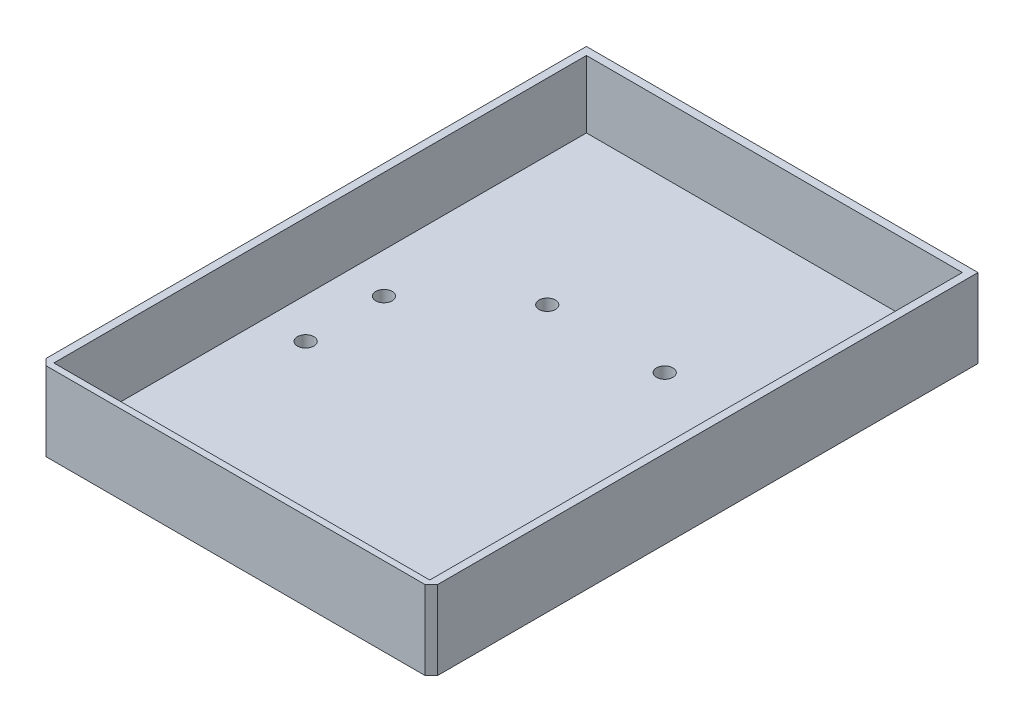
from build123d import *

# Parameters (mm, degrees)
SKETCH6_W            = 100
SKETCH6_H            = 100
SKETCH6_R            = 2.1
BOSS_EXTRUDE2_DEPTH  = 3
SKETCH7_W            = 96
SKETCH7_H            = 2
BOSS_EXTRUDE3_DEPTH  = 3
SKETCH8_W            = 96
SKETCH8_H            = 2
BOSS_EXTRUDE4_DEPTH  = 3
CHAMFER1_SIZE        = 2
BOSS_EXTRUDE5_DEPTH  = 3
SKETCH10_W           = 98
SKETCH10_H           = 25
BOSS_EXTRUDE6_DEPTH  = 2
SKETCH11_W           = 2
SKETCH11_H           = 25
BOSS_EXTRUDE7_DEPTH  = 40
SKETCH12_W           = 138
SKETCH12_H           = 25
BOSS_EXTRUDE8_DEPTH  = 2
CUT_EXTRUDE1_DEPTH   = 3
SKETCH15_W           = 96
SKETCH15_H           = 6.337470387
CUT_EXTRUDE2_DEPTH   = 3
SKETCH16_W           = 96
SKETCH16_H           = 3
BOSS_EXTRUDE9_DEPTH  = 40
SKETCH17_W           = 96
SKETCH17_H           = 2
BOSS_EXTRUDE10_DEPTH = 22
BOSS_EXTRUDE11_DEPTH = 19
SKETCH19_W           = 108.527729828
SKETCH19_H           = 34.099347136
CUT_EXTRUDE3_DEPTH   = 0.4
SKETCH20_W           = 119.4554648
SKETCH20_H           = 149.467416286
CUT_EXTRUDE4_DEPTH   = 4.87


with BuildPart() as part:
    # Sketch6 → Boss-Extrude2 (new body)
    with BuildSketch(Plane(origin=(0, 0, 0), x_dir=(1, 0, 0), z_dir=(0, 1, 0))):
        with Locations((39.444153985, -113.424821635)):
            Rectangle(SKETCH6_W, SKETCH6_H)
        with Locations((1.68480047, -87.360414745)):
            Circle(SKETCH6_R, mode=Mode.SUBTRACT)
        with Locations((1.68480047, -107.360414745)):
            Circle(SKETCH6_R, mode=Mode.SUBTRACT)
        with Locations((1.68480047, -152.360414745)):
            Circle(SKETCH6_R, mode=Mode.SUBTRACT)
        with Locations((24.444153985, -158.424821635)):
            Circle(SKETCH6_R, mode=Mode.SUBTRACT)
        with Locations((24.444153985, -68.424821635)):
            Circle(SKETCH6_R, mode=Mode.SUBTRACT)
        with Locations((54.444153985, -158.424821635)):
            Circle(SKETCH6_R, mode=Mode.SUBTRACT)
        with Locations((77.2035075, -152.360414745)):
            Circle(SKETCH6_R, mode=Mode.SUBTRACT)
        with Locations((77.2035075, -107.360414745)):
            Circle(SKETCH6_R, mode=Mode.SUBTRACT)
        with Locations((77.2035075, -87.360414745)):
            Circle(SKETCH6_R, mode=Mode.SUBTRACT)
        with Locations((54.444153985, -68.424821635)):
            Circle(SKETCH6_R, mode=Mode.SUBTRACT)
    extrude(amount=BOSS_EXTRUDE2_DEPTH)

    # Sketch7 → Boss-Extrude3 (add)
    with BuildSketch(Plane(origin=(0, 3, 0), x_dir=(1, 0, 0), z_dir=(0, 1, 0))):
        Polygon((-10.555846015, -63.424821635), (-10.555846015, -163.424821635), (-8.555846015, -163.424821635), (-8.555846015, -65.424821635), (-8.555846015, -63.424821635), align=None)
        with Locations((39.444153985, -64.424821635)):
            Rectangle(SKETCH7_W, SKETCH7_H)
        Polygon((87.444153985, -63.424821635), (87.444153985, -65.424821635), (87.444153985, -163.424821635), (89.444153985, -163.424821635), (89.444153985, -63.424821635), align=None)
    extrude(amount=BOSS_EXTRUDE3_DEPTH)

    # Sketch8 → Boss-Extrude4 (add)
    with BuildSketch(Plane(origin=(0, 3, 0), x_dir=(1, 0, 0), z_dir=(0, 1, 0))):
        with Locations((39.444153985, -162.424821635)):
            Rectangle(SKETCH8_W, SKETCH8_H)
    extrude(amount=BOSS_EXTRUDE4_DEPTH)

    # Chamfer1
    chamfer1_edges = [part.edges().sort_by_distance(p)[0] for p in [
        (-10.555846015, 3, 63.424821635),
        (89.444153985, 3, 63.424821635),
        (89.444153985, 3, 163.424821635),
        (-10.555846015, 3, 163.424821635),
    ]]
    chamfer(chamfer1_edges, length=CHAMFER1_SIZE)

    # Sketch9 → Boss-Extrude5 (add)
    with BuildSketch(Plane(origin=(0, 3, 0), x_dir=(1, 0, 0), z_dir=(0, 1, 0))):
        Polygon((-6.555846015, -65.424821635), (-8.555846015, -67.424821635), (-8.555846015, -65.424821635), align=None)
        Polygon((87.444153985, -67.424821635), (87.444153985, -65.424821635), (85.444153985, -65.424821635), align=None)
        Polygon((85.444153985, -161.424821635), (87.444153985, -159.424821635), (87.444153985, -161.424821635), align=None)
        Polygon((-8.555846015, -159.424821635), (-8.555846015, -161.424821635), (-6.555846015, -161.424821635), align=None)
    extrude(amount=BOSS_EXTRUDE5_DEPTH)

    # Sketch10 → Boss-Extrude6 (add)
    with BuildSketch(Plane.ZY.offset(10.555846015)):
        with Locations((112.424821635, 12.5)):
            Rectangle(SKETCH10_W, SKETCH10_H)
    extrude(amount=-BOSS_EXTRUDE6_DEPTH)

    # Sketch11 → Boss-Extrude7 (add)
    with BuildSketch(Plane(origin=(0, 0, 63.424821635), x_dir=(-1, 0, 0), z_dir=(0, 0, -1))):
        with Locations((9.555846015, 12.5)):
            Rectangle(SKETCH11_W, SKETCH11_H)
    extrude(amount=BOSS_EXTRUDE7_DEPTH)

    # Sketch12 → Boss-Extrude8 (add)
    with BuildSketch(Plane(origin=(89.444153985, 0, 0), x_dir=(0, 0, -1), z_dir=(1, 0, 0))):
        with Locations((-92.424821635, 12.5)):
            Rectangle(SKETCH12_W, SKETCH12_H)
    extrude(amount=-BOSS_EXTRUDE8_DEPTH)

    # Sketch13 → Cut-Extrude1 (cut)
    with BuildSketch(Plane(origin=(0, 6, 0), x_dir=(1, 0, 0), z_dir=(0, 1, 0))):
        Polygon((-8.555846015, -161.424821635), (-6.555846015, -161.424821635), (-8.555846015, -159.424821635), align=None)
        Polygon((85.444153985, -161.424821635), (87.444153985, -161.424821635), (87.444153985, -159.424821635), align=None)
    extrude(amount=-CUT_EXTRUDE1_DEPTH, mode=Mode.SUBTRACT)

    # Sketch15 → Cut-Extrude2 (cut)
    with BuildSketch(Plane(origin=(0, 6, 0), x_dir=(1, 0, 0), z_dir=(0, 1, 0))):
        with Locations((39.444153985, -66.593556828)):
            Rectangle(SKETCH15_W, SKETCH15_H)
    extrude(amount=-CUT_EXTRUDE2_DEPTH, mode=Mode.SUBTRACT)

    # Sketch16 → Boss-Extrude9 (add)
    with BuildSketch(Plane(origin=(0, 0, 63.424821635), x_dir=(-1, 0, 0), z_dir=(0, 0, -1))):
        with Locations((-39.444153985, 1.5)):
            Rectangle(SKETCH16_W, SKETCH16_H)
    extrude(amount=BOSS_EXTRUDE9_DEPTH)

    # Sketch17 → Boss-Extrude10 (add)
    with BuildSketch(Plane(origin=(0, 3, 0), x_dir=(1, 0, 0), z_dir=(0, 1, 0))):
        with Locations((39.444153985, -24.424821635)):
            Rectangle(SKETCH17_W, SKETCH17_H)
    extrude(amount=BOSS_EXTRUDE10_DEPTH)

    # Sketch18 → Boss-Extrude11 (add)
    with BuildSketch(Plane(origin=(0, 6, 0), x_dir=(1, 0, 0), z_dir=(0, 1, 0))):
        Polygon((-10.555846015, -161.424821635), (-8.555846015, -163.424821635), (87.444153985, -163.424821635), (89.444153985, -161.424821635), align=None)
    extrude(amount=BOSS_EXTRUDE11_DEPTH)

    # Sketch19 → Cut-Extrude3 (cut)
    with BuildSketch(Plane.XY.offset(163.424821635)):
        with Locations((38.077994244, 12.109002602)):
            Rectangle(SKETCH19_W, SKETCH19_H)
    extrude(amount=-CUT_EXTRUDE3_DEPTH, mode=Mode.SUBTRACT)

    # Sketch20 → Cut-Extrude4 (cut)
    with BuildSketch(Plane(origin=(0, 25, 0), x_dir=(1, 0, 0), z_dir=(0, 1, 0))):
        with Locations((42.445417515, -94.60695098)):
            Rectangle(SKETCH20_W, SKETCH20_H)
    extrude(amount=-CUT_EXTRUDE4_DEPTH, mode=Mode.SUBTRACT)


solid = part.part
